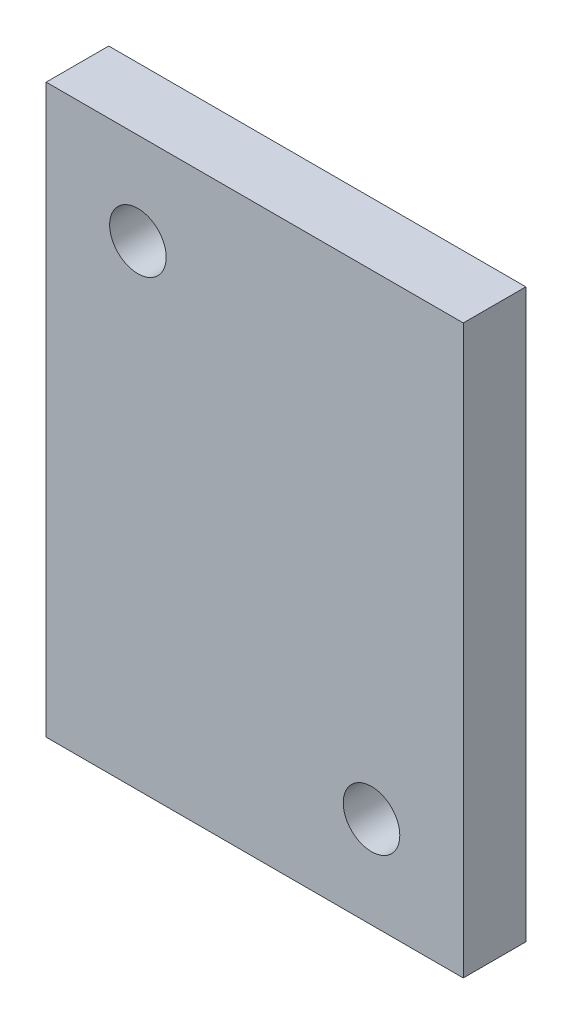
from build123d import *

# Parameters (mm, degrees)
SKETCH1_W             = 31.75
SKETCH1_H             = 43.18
BOSS_EXTRUDE1_DEPTH   = 4.7625
F_6_CLEARANCE_HOLE1_D = 4.3053


with BuildPart() as part:
    # Sketch1 → Boss-Extrude1 (new body)
    with BuildSketch(Plane.XY):
        with Locations((-3085.283757164, 1098.230694712)):
            Rectangle(SKETCH1_W, SKETCH1_H)
    extrude(amount=BOSS_EXTRUDE1_DEPTH)

    # #6 Clearance Hole1 (through all)
    with Locations(Plane.XY.offset(4.7625)):
        with Locations((-3076.393757164, 1083.625694712), (-3094.173757164, 1112.835694712)):
            Hole(F_6_CLEARANCE_HOLE1_D / 2)


solid = part.part
